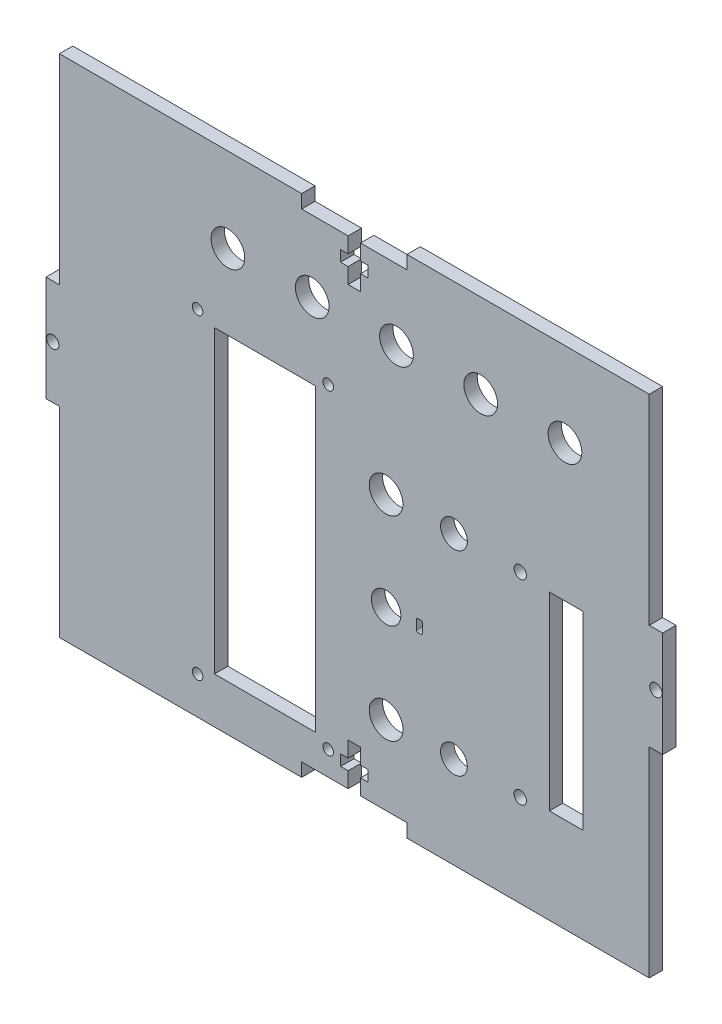
from build123d import *

# Parameters (mm, degrees)
SKETCH1_R           = 1.47
BOSS_EXTRUDE1_DEPTH = 1.5875
SKETCH3_W           = 8
SKETCH3_H           = 45
CUT_EXTRUDE1_DEPTH  = 4.175
SKETCH4_W           = 24
SKETCH4_H           = 71.2
CUT_EXTRUDE2_DEPTH  = 4.175
CUT_EXTRUDE4_DEPTH  = 4.175
SKETCH6_R           = 4
CUT_EXTRUDE5_DEPTH  = 4.175
SKETCH9_R           = 1.25
SKETCH9_R_2         = 1.47
CUT_EXTRUDE6_DEPTH  = 4.175
SKETCH12_R          = 4
SKETCH12_R_2        = 3.5
SKETCH12_R_3        = 3.175
CUT_EXTRUDE7_DEPTH  = 4.175


with BuildPart() as part:
    # Sketch1 → Boss-Extrude1 (new body, symmetric)
    with BuildSketch(Plane.XY):
        Polygon((-12.5, 60), (-70, 60), (-70, 12.5), (-73.175, 12.5), (-73.175, -12.5), (-70, -12.5), (-70, -60), (-12.5, -60), (-12.5, -56.825), (-1.47, -56.825), (-1.47, -53.125), (-3.25, -53.125), (-3.25, -50.525), (-1.47, -50.525), (-1.47, -46.825), (1.47, -46.825), (1.47, -50.525), (3.25, -50.525), (3.25, -53.125), (1.47, -53.125), (1.47, -56.825), (12.5, -56.825), (12.5, -60), (70, -60), (70, -12.5), (73.175, -12.5), (73.175, 12.5), (70, 12.5), (70, 60), (12.5, 60), (12.5, 56.825), (1.47, 56.825), (1.47, 53.125), (3.25, 53.125), (3.25, 50.525), (1.47, 50.525), (1.47, 46.825), (-1.47, 46.825), (-1.47, 50.525), (-3.25, 50.525), (-3.25, 53.125), (-1.47, 53.125), (-1.47, 56.825), (-12.5, 56.825), align=None)
        with Locations((-71.5875, 0)):
            Circle(SKETCH1_R, mode=Mode.SUBTRACT)
        with Locations((71.5875, 0)):
            Circle(SKETCH1_R, mode=Mode.SUBTRACT)
    extrude(amount=BOSS_EXTRUDE1_DEPTH, both=True)

    # Sketch3 → Cut-Extrude1 (cut, through all)
    with BuildSketch(Plane(origin=(0, 0, -1.5875), x_dir=(-1, 0, 0), z_dir=(0, 0, -1))):
        with Locations((-50.3, -15)):
            Rectangle(SKETCH3_W, SKETCH3_H)
    extrude(amount=-CUT_EXTRUDE1_DEPTH, mode=Mode.SUBTRACT)

    # Sketch4 → Cut-Extrude2 (cut, through all)
    with BuildSketch(Plane(origin=(0, 0, -1.5875), x_dir=(-1, 0, 0), z_dir=(0, 0, -1))):
        with Locations((21.2, -13.494459363)):
            Rectangle(SKETCH4_W, SKETCH4_H)
    extrude(amount=-CUT_EXTRUDE2_DEPTH, mode=Mode.SUBTRACT)

    # Sketch5 → Cut-Extrude4 (cut, through all)
    with BuildSketch(Plane(origin=(0, 0, -1.5875), x_dir=(-1, 0, 0), z_dir=(0, 0, -1))):
        with BuildLine():
            Line((-15.153420736, -16.45), (-15.77915134, -16.45))
            ThreePointArc((-15.77915134, -16.45), (-16.043498683, -16.350200736), (-16.175937675, -16.10060241))
            ThreePointArc((-16.175937675, -16.10060241), (-16.245834875, -15), (-16.175937675, -13.89939759))
            ThreePointArc((-16.175937675, -13.89939759), (-16.043498683, -13.649799264), (-15.77915134, -13.55))
            Line((-15.77915134, -13.55), (-15.153420736, -13.55))
            ThreePointArc((-15.153420736, -13.55), (-14.870578023, -13.667157288), (-14.753420736, -13.95))
            Line((-14.753420736, -13.95), (-14.753420736, -16.05))
            ThreePointArc((-14.753420736, -16.05), (-14.870578023, -16.332842712), (-15.153420736, -16.45))
        make_face()
    extrude(amount=-CUT_EXTRUDE4_DEPTH, mode=Mode.SUBTRACT)

    # Sketch6 → Cut-Extrude5 (cut, through all)
    with BuildSketch(Plane(origin=(0, 0, -1.5875), x_dir=(-1, 0, 0), z_dir=(0, 0, -1))):
        with Locations((30, 40)):
            Circle(SKETCH6_R)
        with Locations((10, 40)):
            Circle(SKETCH6_R)
        with Locations((-10, 40)):
            Circle(SKETCH6_R)
        with Locations((-30, 40)):
            Circle(SKETCH6_R)
        with Locations((-50, 40)):
            Circle(SKETCH6_R)
    extrude(amount=-CUT_EXTRUDE5_DEPTH, mode=Mode.SUBTRACT)

    # Sketch9 → Cut-Extrude6 (cut, through all)
    with BuildSketch(Plane.XY.offset(1.5875)):
        with Locations((-37.2, 23.905540637)):
            Circle(SKETCH9_R)
        with Locations((-6.2, 23.905540637)):
            Circle(SKETCH9_R)
        with Locations((-6.2, -51.094459363)):
            Circle(SKETCH9_R)
        with Locations((-37.2, -51.094459363)):
            Circle(SKETCH9_R)
        with Locations((39.3875, 8.16125846)):
            Circle(SKETCH9_R_2)
        with Locations((39.3875, -38.16125846)):
            Circle(SKETCH9_R_2)
    extrude(amount=-CUT_EXTRUDE6_DEPTH, mode=Mode.SUBTRACT)

    # Sketch12 → Cut-Extrude7 (cut, through all)
    with BuildSketch(Plane(origin=(0, 0, -1.5875), x_dir=(-1, 0, 0), z_dir=(0, 0, -1))):
        with Locations((-7.545834875, -38.16125846)):
            Circle(SKETCH12_R)
        with Locations((-7.545834875, 8.16125846)):
            Circle(SKETCH12_R)
        with Locations((-7.545834875, -15)):
            Circle(SKETCH12_R_2)
        with Locations((-23.65, -38.16125846)):
            Circle(SKETCH12_R_3)
        with Locations((-23.65, 8.16125846)):
            Circle(SKETCH12_R_3)
    extrude(amount=-CUT_EXTRUDE7_DEPTH, mode=Mode.SUBTRACT)


solid = part.part
